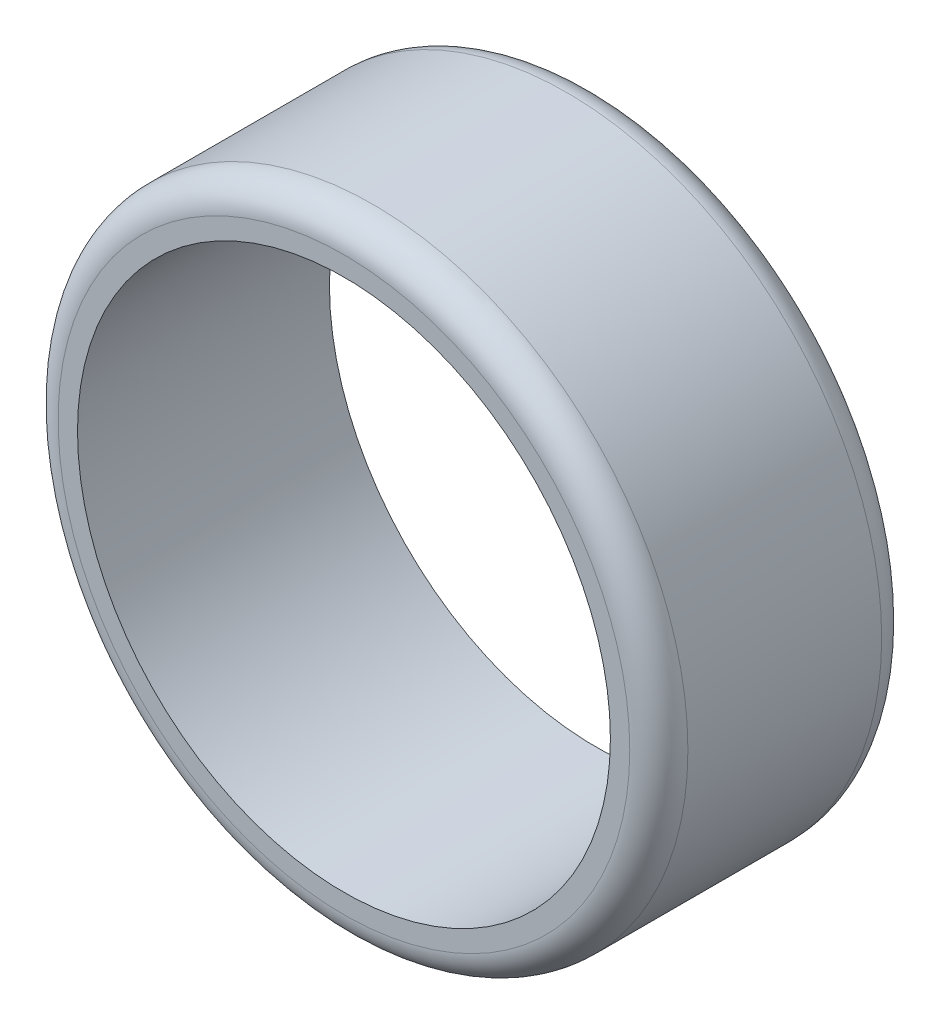
from build123d import *

# Parameters (mm, degrees)
SKETCH1_R           = 32.5
SKETCH1_R_2         = 27.5
BOSS_EXTRUDE1_DEPTH = 26
FILLET1_R           = 3


with BuildPart() as part:
    # Sketch1 → Boss-Extrude1 (new body)
    with BuildSketch(Plane.XY):
        Circle(SKETCH1_R)
        Circle(SKETCH1_R_2, mode=Mode.SUBTRACT)
    extrude(amount=BOSS_EXTRUDE1_DEPTH)

    # Fillet1
    fillet1_edges = [part.edges().sort_by_distance(p)[0] for p in [
        (-32.5, 0, 0),
        (-32.5, 0, 26),
    ]]
    fillet(fillet1_edges, radius=FILLET1_R)


solid = part.part
